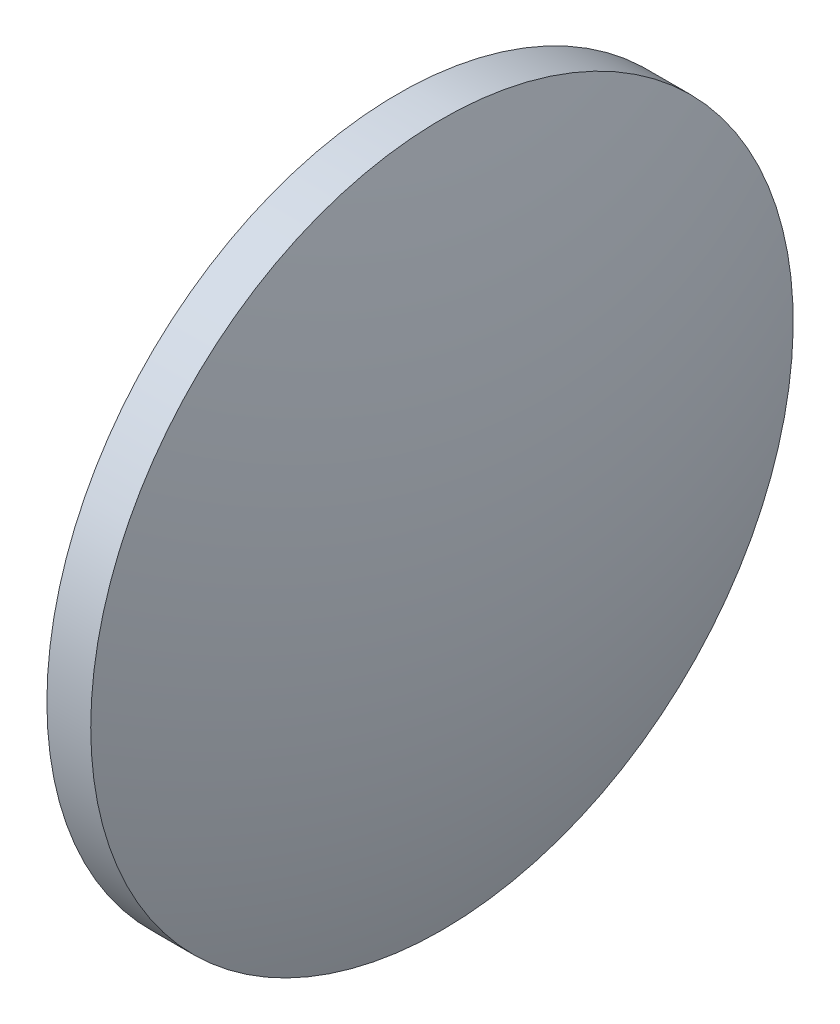
from build123d import *


with BuildPart() as part:
    # 草图2 → 旋转2 (revolve)
    with BuildSketch(Plane.XY, mode=Mode.PRIVATE) as revolve_2_sk:
        with BuildLine():
            Line((700.648213782, 248.698951534), (700.648213782, 261.198951534))
            Line((700.648213782, 261.198951534), (702.208213782, 261.198951534))
            ThreePointArc((702.208213782, 261.198951534), (703.734862401, 255.031636588), (704.248213782, 248.698951534))
            Line((704.248213782, 248.698951534), (700.648213782, 248.698951534))
        make_face()
    revolve(revolve_2_sk.sketch.rotate(Axis((677.000088815, 248.698951534, 0), (1, 0, 0)), 180), axis=Axis((677.000088815, 248.698951534, 0), (1, 0, 0)))  # turned: the seam where the file's is


solid = part.part
